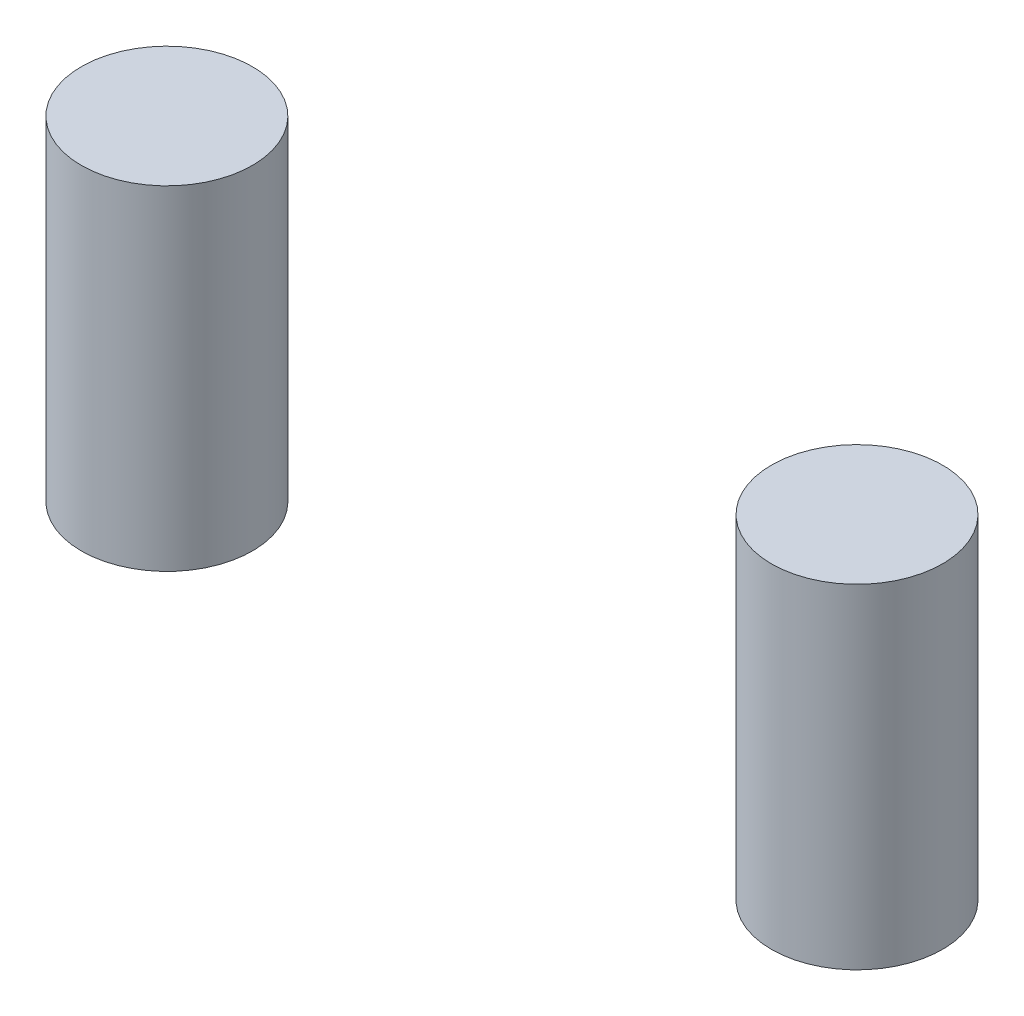
from build123d import *

# Parameters (mm, degrees)
SKETCH1_R             = 3.075
BOSS_EXTRUDE1_DEPTH   = 12
BOSS_EXTRUDE1_2_DEPTH = 12


with BuildPart() as part:
    # Sketch1 → Boss-Extrude1 (new body)
    with BuildSketch(Plane(origin=(0, 0, 0), x_dir=(1, 0, 0), z_dir=(0, 1, 0))):
        with Locations((3.099999428, -3.099999905)):
            Circle(SKETCH1_R)
    extrude(amount=BOSS_EXTRUDE1_DEPTH)


with BuildPart() as body_2:
    # Sketch1 → Boss-Extrude1 2 (new body)
    with BuildSketch(Plane(origin=(0, 0, 0), x_dir=(1, 0, 0), z_dir=(0, 1, 0))):
        with Locations((27.899999428, -3.099999905)):
            Circle(SKETCH1_R)
    extrude(amount=BOSS_EXTRUDE1_2_DEPTH)


solid = Compound([part.part, body_2.part])
